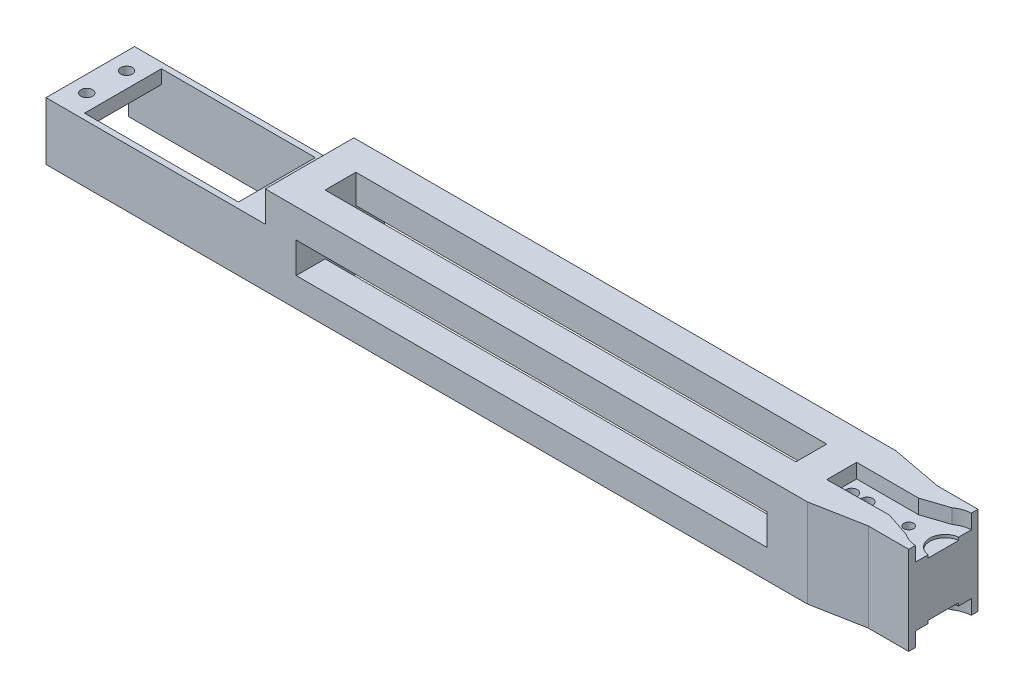
from build123d import *

# Parameters (mm, degrees)
BOSS_EXTRUDE1_DEPTH = 11.5
SKETCH1_13_R        = 1.5
SKETCH1_13_R_2      = 1.25
BOSS_EXTRUDE2_DEPTH = 7.75
BOSS_EXTRUDE3_DEPTH = 7
SKETCH2_W           = 23
SKETCH2_H           = 23
BOSS_EXTRUDE4_DEPTH = 190
CUT_EXTRUDE1_DEPTH  = 57
SKETCH8_W           = 57.001402056
SKETCH8_H           = 19.999995634
CUT_EXTRUDE5_DEPTH  = 11.5
SKETCH8_6_W         = 40.001402056
SKETCH8_6_H         = 19.999995634
SKETCH8_6_R         = 1.5
CUT_EXTRUDE7_DEPTH  = 15.55
SKETCH11_W          = 122.346056991
SKETCH11_H          = 8
CUT_EXTRUDE8_DEPTH  = 85.55
SKETCH10_W          = 122.346056991
SKETCH10_H          = 8
CUT_EXTRUDE9_DEPTH  = 105.55


with BuildPart() as part:
    # Sketch1 → Boss-Extrude1 (new, symmetric)
    with BuildSketch(Plane(origin=(0, 0, 0), x_dir=(1, 0, 0), z_dir=(0, 1, 0))):
        with BuildLine():
            Line((6.824314586, 7.284360201), (6.824314586, 9.00020274))
            Line((6.824314586, 9.00020274), (-3.690467309, 9.00020274))
            Line((-3.690467309, 9.00020274), (-17.038497557, 11.5))
            Line((-17.038497557, 11.5), (-24.867971487, 11.5))
            Line((-24.867971487, 11.5), (-24.867971487, -11.5))
            Line((-24.867971487, -11.5), (-17.038497557, -11.5))
            Line((-17.038497557, -11.5), (-3.690467309, -9.00020274))
            Line((-3.690467309, -9.00020274), (6.824314586, -9.00020274))
            Line((6.824314586, -9.00020274), (6.824314586, -7.284360201))
            ThreePointArc((6.824314586, -7.284360201), (4.861171432, -6.879883717), (3.082035449, -5.956732906))
            Line((3.082035449, -5.956732906), (-3.422402494, -3.8))
            Line((-3.422402494, -3.8), (-19.513448301, -3.98254267))
            Line((-19.513448301, -3.98254267), (-19.513448301, 3.8))
            Line((-19.513448301, 3.8), (-3.422402494, 3.8))
            Line((-3.422402494, 3.8), (3.082035449, 5.956732906))
            ThreePointArc((3.082035449, 5.956732906), (4.861171432, 6.879883717), (6.824314586, 7.284360201))
        make_face()
    extrude(amount=BOSS_EXTRUDE1_DEPTH, both=True)

    # Sketch1_13 → Boss-Extrude2 (add, symmetric)
    with BuildSketch(Plane(origin=(0, 0, 0), x_dir=(1, 0, 0), z_dir=(0, 1, 0))):
        with BuildLine():
            Line((6.824314586, 3.971385595), (6.824314586, 7.284360201))
            ThreePointArc((6.824314586, 7.284360201), (4.861171432, 6.879883717), (3.082035449, 5.956732906))
            Line((3.082035449, 5.956732906), (-3.422402494, 3.8))
            Line((-3.422402494, 3.8), (-19.513448301, 3.8))
            Line((-19.513448301, 3.8), (-19.513448301, -3.98254267))
            Line((-19.513448301, -3.98254267), (-3.422402494, -3.8))
            Line((-3.422402494, -3.8), (3.082035449, -5.956732906))
            ThreePointArc((3.082035449, -5.956732906), (4.861171432, -6.879883717), (6.824314586, -7.284360201))
            Line((6.824314586, -7.284360201), (6.824314586, -3.971385595))
            ThreePointArc((6.824314586, -3.971385595), (3.301909035, 0), (6.824314586, 3.971385595))
        make_face()
        with Locations((-17.038497557, 0)):
            Circle(SKETCH1_13_R, mode=Mode.SUBTRACT)
        with Locations((-13.038497557, 0)):
            Circle(SKETCH1_13_R, mode=Mode.SUBTRACT)
        with Locations((-2.172402494, 0)):
            Circle(SKETCH1_13_R_2, mode=Mode.SUBTRACT)
    extrude(amount=BOSS_EXTRUDE2_DEPTH, both=True)

    # Sketch1_14 → Boss-Extrude3 (add, symmetric)
    with BuildSketch(Plane(origin=(0, 0, 0), x_dir=(1, 0, 0), z_dir=(0, 1, 0))):
        with BuildLine():
            Line((6.824314586, -3.971385595), (6.824314586, 3.971385595))
            ThreePointArc((6.824314586, 3.971385595), (3.301909035, 0), (6.824314586, -3.971385595))
        make_face()
    extrude(amount=BOSS_EXTRUDE3_DEPTH, both=True)

    # Sketch2 → Boss-Extrude4 (add)
    with BuildSketch(Plane.ZY.offset(24.867971487)):
        Rectangle(SKETCH2_W, SKETCH2_H)
    extrude(amount=BOSS_EXTRUDE4_DEPTH)

    # Sketch9 → Cut-Extrude1 (cut)
    with BuildSketch(Plane.ZY.offset(214.867971487)):
        Polygon((-12.112347762, 3.545517382), (11.5, 3.545517382), (11.5, 11.5), (-11.5, 11.5), (-12.112347762, 11.5), align=None)
    extrude(amount=-CUT_EXTRUDE1_DEPTH, mode=Mode.SUBTRACT)

    # Sketch8 → Cut-Extrude5 (cut)
    with BuildSketch(Plane.XZ.offset(11.5)):
        with Locations((-186.367270459, 2.183e-06)):
            Rectangle(SKETCH8_W, SKETCH8_H)
    extrude(amount=-CUT_EXTRUDE5_DEPTH, mode=Mode.SUBTRACT)

    # Sketch8_6 → Cut-Extrude7 (cut)
    with BuildSketch(Plane.XZ.offset(11.5)):
        with Locations((-186.367270459, 2.183e-06)):
            Rectangle(SKETCH8_6_W, SKETCH8_6_H)
        with Locations((-210.617971487, 5.162283196)):
            Circle(SKETCH8_6_R)
        with Locations((-210.439498104, -5.010019091)):
            Circle(SKETCH8_6_R)
        with Locations((-162.116569431, 5.124855295)):
            Circle(SKETCH8_6_R)
        with Locations((-162.171918624, -5.125135232)):
            Circle(SKETCH8_6_R)
    extrude(amount=-CUT_EXTRUDE7_DEPTH, mode=Mode.SUBTRACT)

    # Sketch11 → Cut-Extrude8 (cut)
    with BuildSketch(Plane.XY.offset(11.5)):
        with Locations((-88.686476797, 0)):
            Rectangle(SKETCH11_W, SKETCH11_H)
    extrude(amount=-CUT_EXTRUDE8_DEPTH, mode=Mode.SUBTRACT)

    # Sketch10 → Cut-Extrude9 (cut)
    with BuildSketch(Plane(origin=(0, 11.5, 0), x_dir=(1, 0, 0), z_dir=(0, 1, 0))):
        with Locations((-88.686476797, 0.01745733)):
            Rectangle(SKETCH10_W, SKETCH10_H)
    extrude(amount=-CUT_EXTRUDE9_DEPTH, mode=Mode.SUBTRACT)


solid = part.part
